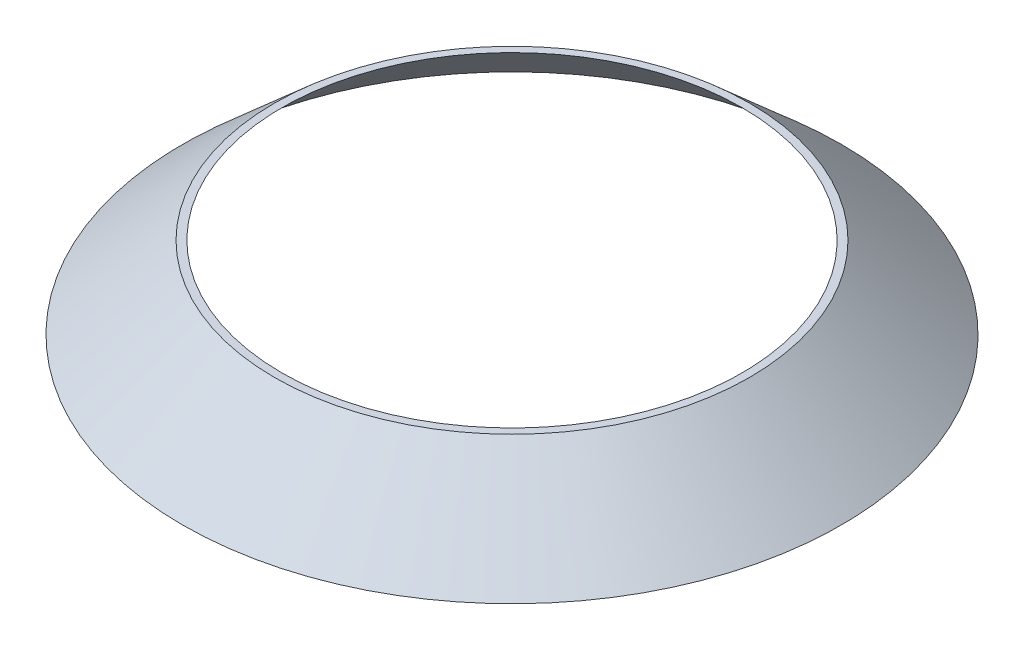
from build123d import *

# Parameters (mm, degrees)
SKETCH1_R    = 32.25
SKETCH2_R    = 23.25
SKETCH2_5_R  = 22.5
SKETCH1_52_R = 31.5


with BuildPart() as part:
    # Sketch1 → Loft2 section 0
    with BuildSketch(Plane(origin=(0, 0, 0), x_dir=(1, 0, 0), z_dir=(0, 1, 0))):
        Circle(SKETCH1_R)
    # Sketch2 → Loft2 section 1
    with BuildSketch(Plane(origin=(0, 8, 0), x_dir=(1, 0, 0), z_dir=(0, 1, 0))):
        Circle(SKETCH2_R)
    loft()

    # Sketch2_5 → Cut-Loft1 section 0
    with BuildSketch(Plane(origin=(0, 8, 0), x_dir=(1, 0, 0), z_dir=(0, 1, 0))):
        Circle(SKETCH2_5_R)
    # Sketch1_52 → Cut-Loft1 section 1
    with BuildSketch(Plane(origin=(0, 0, 0), x_dir=(1, 0, 0), z_dir=(0, 1, 0))):
        Circle(SKETCH1_52_R)
    loft(mode=Mode.SUBTRACT)


solid = part.part
